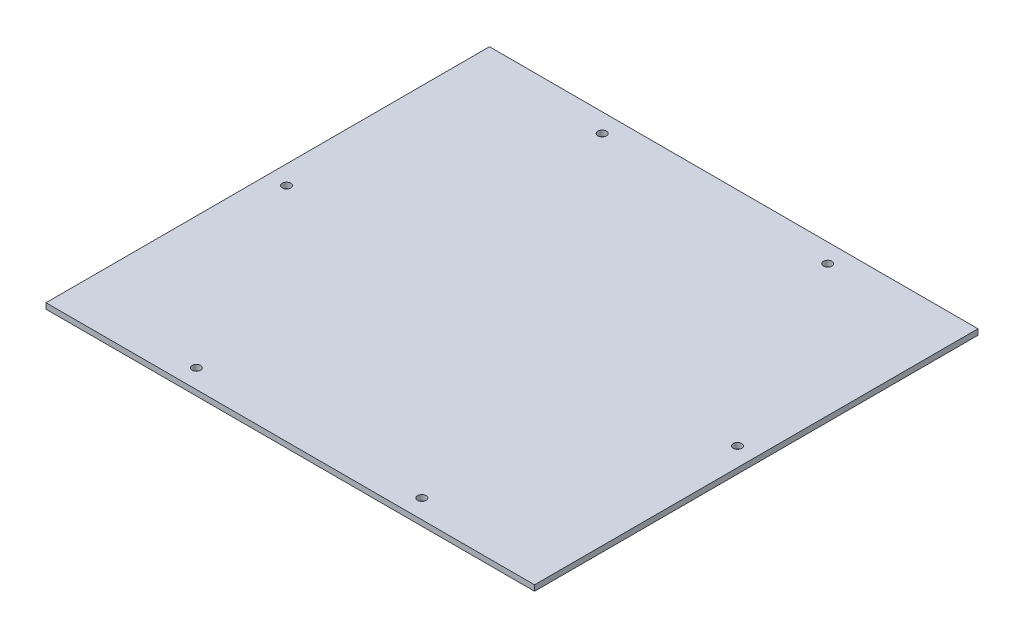
from build123d import *

# Parameters (mm, degrees)
SKETCH_1_W          = 260
SKETCH_1_H          = 236
EXTRUDE_1_DEPTH     = 3
SKETCH_2_R          = 2.25
CUT_EXTRUDE_1_DEPTH = 4


with BuildPart() as part:
    # Эскиз1 → Бобышка-Вытянуть1 (new body)
    with BuildSketch(Plane(origin=(0, 30, 0), x_dir=(1, 0, 0), z_dir=(0, 1, 0))):
        with Locations((-94.330876849, -118.064509681)):
            Rectangle(SKETCH_1_W, SKETCH_1_H)
    extrude(amount=EXTRUDE_1_DEPTH)

    # Эскиз2 → Вырез-Вытянуть1 (cut, through all)
    with BuildSketch(Plane(origin=(0, 33, 0), x_dir=(1, 0, 0), z_dir=(0, 1, 0))):
        with Locations((-214.330876849, -118.064509681)):
            Circle(SKETCH_2_R)
        with Locations((-154.330876849, -10.064509681)):
            Circle(SKETCH_2_R)
        with Locations((-34.330876849, -10.064509681)):
            Circle(SKETCH_2_R)
        with Locations((-154.330876849, -226.064509681)):
            Circle(SKETCH_2_R)
        with Locations((-34.330876849, -226.064509681)):
            Circle(SKETCH_2_R)
        with Locations((25.669123151, -118.064509681)):
            Circle(SKETCH_2_R)
    extrude(amount=-CUT_EXTRUDE_1_DEPTH, mode=Mode.SUBTRACT)


solid = part.part
